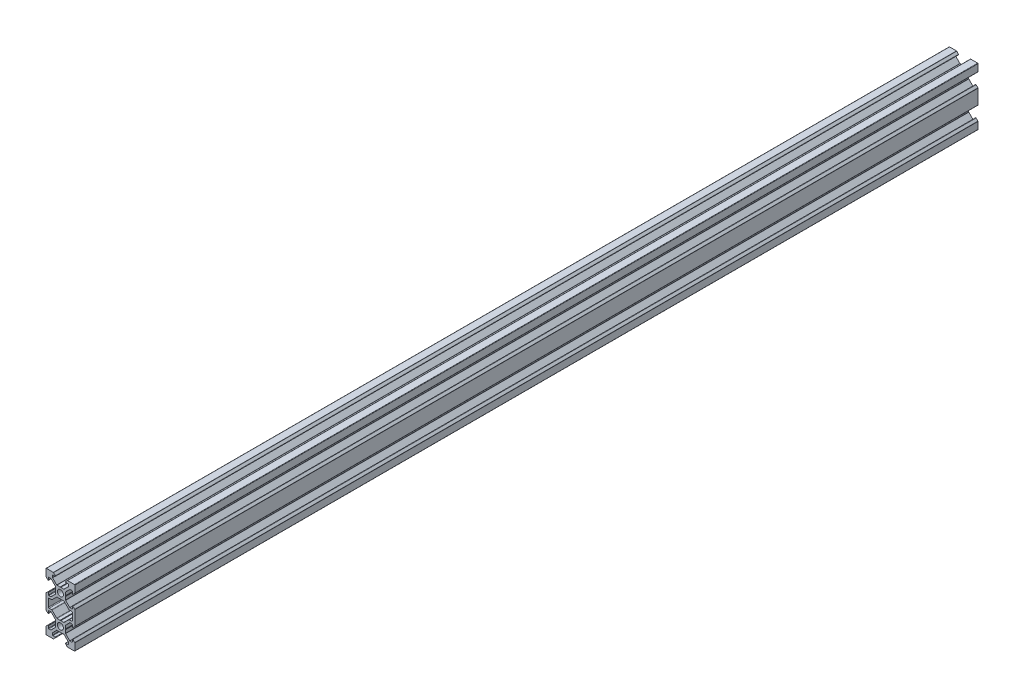
from build123d import *

# Parameters (mm, degrees)
SKETCH1_R           = 2.1
BOSS_EXTRUDE1_DEPTH = 627
FILLET1_R           = 0.25
FILLET2_R           = 0.5
CUT_EXTRUDE1_DEPTH  = 628


with BuildPart() as part:
    # Sketch1 → Boss-Extrude1 (new body)
    with BuildSketch(Plane.XY):
        Polygon((3.560660172, -2.5), (3.560660172, 2.5), (6.560660172, 5.5), (8.252142372, 5.5), (8.252142372, 3.1), (10, 4.847857628), (10, 10), (4.847857628, 10), (3.1, 8.252142372), (5.5, 8.252142372), (5.5, 6.560660172), (2.5, 3.560660172), (-2.5, 3.560660172), (-5.5, 6.560660172), (-5.5, 8.252142372), (-3.1, 8.252142372), (-4.847857628, 10), (-10, 10), (-10, 4.847857628), (-8.252142372, 3.1), (-8.252142372, 5.5), (-6.560660172, 5.5), (-3.560660172, 2.5), (-3.560660172, -2.5), (-6.560660172, -5.5), (-8.252142372, -5.5), (-8.252142372, -3.1), (-10, -4.847857628), (-10, -7), (-10, -13), (-10, -15.152142372), (-8.252142372, -16.9), (-8.252142372, -14.5), (-6.560660172, -14.5), (-3.560660172, -17.5), (-3.560660172, -22.5), (-6.560660172, -25.5), (-8.252142372, -25.5), (-8.252142372, -23.1), (-10, -24.847857628), (-10, -30), (-4.847857628, -30), (-3.1, -28.252142372), (-5.5, -28.252142372), (-5.5, -26.560660172), (-2.5, -23.560660172), (2.5, -23.560660172), (5.5, -26.560660172), (5.5, -28.252142372), (3.1, -28.252142372), (4.847857628, -30), (10, -30), (10, -24.847857628), (8.252142372, -23.1), (8.252142372, -25.5), (6.560660172, -25.5), (3.560660172, -22.5), (3.560660172, -17.5), (6.560660172, -14.5), (8.252142372, -14.5), (8.252142372, -16.9), (10, -15.152142372), (10, -13), (10, -7), (10, -4.847857628), (8.252142372, -3.1), (8.252142372, -5.5), (6.560660172, -5.5), align=None)
        Circle(SKETCH1_R, mode=Mode.SUBTRACT)
        with Locations((0, -20)):
            Circle(SKETCH1_R, mode=Mode.SUBTRACT)
        Polygon((2.5, -3.560660172), (-2.5, -3.560660172), (-5.5, -6.560660172), (-5.939339828, -7), (-8.252142372, -7), (-8.252142372, -13), (-5.939339828, -13), (-5.5, -13.439339828), (-2.5, -16.439339828), (2.5, -16.439339828), (5.5, -13.439339828), (5.939339828, -13), (8.252142372, -13), (8.252142372, -7), (5.939339828, -7), (5.5, -6.560660172), align=None, mode=Mode.SUBTRACT)
    extrude(amount=BOSS_EXTRUDE1_DEPTH)

    # Fillet1
    fillet1_edges = [part.edges().sort_by_distance(p)[0] for p in [
        (5.5, 6.560660172, 313.5),
        (5.5, 8.252142372, 313.5),
        (3.1, 8.252142372, 313.5),
        (4.847857628, 10, 313.5),
        (10, 10, 313.5),
        (10, 4.847857628, 313.5),
        (8.252142372, 3.1, 313.5),
        (8.252142372, 5.5, 313.5),
        (6.560660172, 5.5, 313.5),
        (3.560660172, 2.5, 313.5),
        (3.560660172, -2.5, 313.5),
        (6.560660172, -5.5, 313.5),
        (8.252142372, -5.5, 313.5),
        (8.252142372, -3.1, 313.5),
        (10, -4.847857628, 313.5),
        (10, -15.152142372, 313.5),
        (8.252142372, -16.9, 313.5),
        (8.252142372, -14.5, 313.5),
        (6.560660172, -14.5, 313.5),
        (3.560660172, -17.5, 313.5),
        (3.560660172, -22.5, 313.5),
        (6.560660172, -25.5, 313.5),
        (8.252142372, -25.5, 313.5),
        (8.252142372, -23.1, 313.5),
        (10, -24.847857628, 313.5),
        (10, -30, 313.5),
        (4.847857628, -30, 313.5),
        (3.1, -28.252142372, 313.5),
        (5.5, -28.252142372, 313.5),
        (5.5, -26.560660172, 313.5),
        (2.5, -23.560660172, 313.5),
        (-2.5, -23.560660172, 313.5),
        (-5.5, -26.560660172, 313.5),
        (-5.5, -28.252142372, 313.5),
        (-3.1, -28.252142372, 313.5),
        (-4.847857628, -30, 313.5),
        (-10, -30, 313.5),
        (-10, -24.847857628, 313.5),
        (-8.252142372, -23.1, 313.5),
        (-8.252142372, -25.5, 313.5),
        (-6.560660172, -25.5, 313.5),
        (-3.560660172, -22.5, 313.5),
        (-3.560660172, -17.5, 313.5),
        (-6.560660172, -14.5, 313.5),
        (-8.252142372, -14.5, 313.5),
        (-8.252142372, -16.9, 313.5),
        (-10, -15.152142372, 313.5),
        (-10, -4.847857628, 313.5),
        (-8.252142372, -3.1, 313.5),
        (-8.252142372, -5.5, 313.5),
        (-6.560660172, -5.5, 313.5),
        (-3.560660172, -2.5, 313.5),
        (-3.560660172, 2.5, 313.5),
        (-6.560660172, 5.5, 313.5),
        (-8.252142372, 5.5, 313.5),
        (-8.252142372, 3.1, 313.5),
        (-10, 4.847857628, 313.5),
        (-10, 10, 313.5),
        (-4.847857628, 10, 313.5),
        (-3.1, 8.252142372, 313.5),
        (-5.5, 8.252142372, 313.5),
        (-5.5, 6.560660172, 313.5),
        (-2.5, 3.560660172, 313.5),
        (2.5, 3.560660172, 313.5),
    ]]
    fillet(fillet1_edges, radius=FILLET1_R)

    # Fillet2
    fillet2_edges = [part.edges().sort_by_distance(p)[0] for p in [
        (-2.5, -3.560660172, 313.5),
        (-5.939339828, -7, 313.5),
        (-8.252142372, -7, 313.5),
        (-8.252142372, -13, 313.5),
        (-5.939339828, -13, 313.5),
        (-2.5, -16.439339828, 313.5),
        (2.5, -16.439339828, 313.5),
        (5.939339828, -13, 313.5),
        (8.252142372, -13, 313.5),
        (8.252142372, -7, 313.5),
        (5.939339828, -7, 313.5),
        (2.5, -3.560660172, 313.5),
    ]]
    fillet(fillet2_edges, radius=FILLET2_R)

    # Sketch2 → Cut-Extrude1 (cut, through all)
    with BuildSketch(Plane.XY.offset(627)):
        Polygon((0, 3.398953432), (-0.242280927, 3.560660172), (0.242280927, 3.560660172), align=None)
        Polygon((0, -3.398953432), (0.242280927, -3.560660172), (-0.242280927, -3.560660172), align=None)
        Polygon((3.560660172, 0.242280927), (3.560660172, -0.242280927), (3.398953432, 0), align=None)
        Polygon((-3.560660172, 0.242280927), (-3.560660172, -0.242280927), (-3.398953432, 0), align=None)
        Polygon((-3.398953432, -20), (-3.560660172, -20.242280927), (-3.560660172, -19.757719073), align=None)
        Polygon((3.398953432, -20), (3.560660172, -19.757719073), (3.560660172, -20.242280927), align=None)
        Polygon((-0.242280927, -16.439339828), (0.242280927, -16.439339828), (0, -16.601046568), align=None)
        Polygon((-0.242280927, -23.560660172), (0.242280927, -23.560660172), (0, -23.398953432), align=None)
    extrude(amount=-CUT_EXTRUDE1_DEPTH, mode=Mode.SUBTRACT)


solid = part.part
